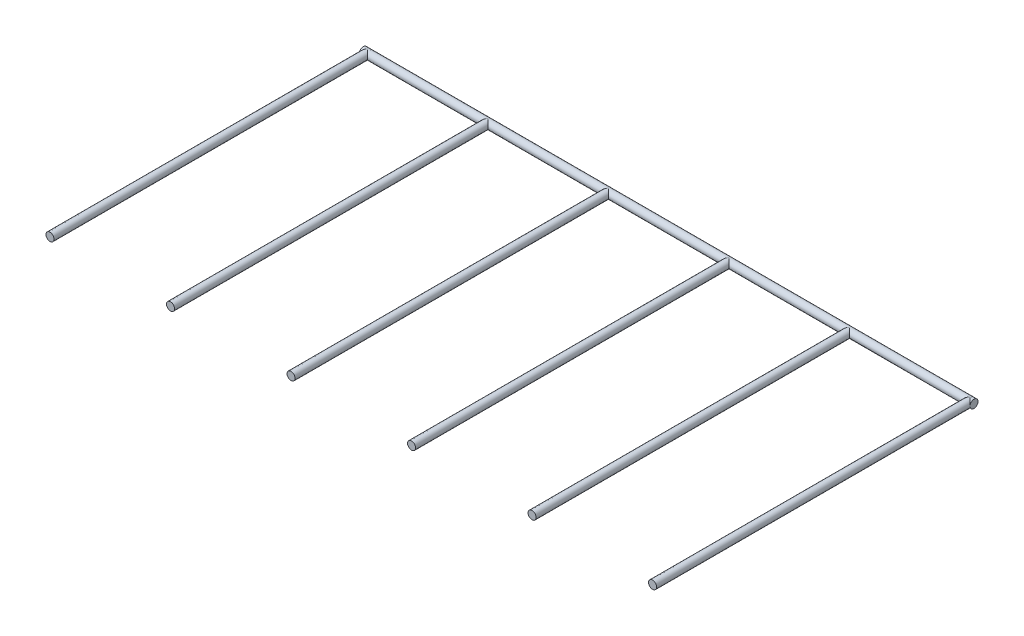
from build123d import *

# Parameters (mm, degrees)
SKETCH1_R           = 1.5875
BOSS_EXTRUDE1_DEPTH = 120.65
SKETCH3_R           = 1.5875
BOSS_EXTRUDE2_DEPTH = 125.4125
LPATTERN1_COUNT     = 6
LPATTERN1_PITCH     = 47.625


with BuildPart() as part:
    # Sketch1 → Boss-Extrude1 (new body, symmetric)
    with BuildSketch(Plane(origin=(0, 0, 0), x_dir=(0, 0, -1), z_dir=(1, 0, 0))):
        Circle(SKETCH1_R)
    extrude(amount=BOSS_EXTRUDE1_DEPTH, both=True)

    # Sketch3 → Boss-Extrude2 (add)
    with BuildSketch(Plane.XY):
        with Locations((-119.0625, 0)):
            Circle(SKETCH3_R)
    boss_extrude2 = extrude(amount=BOSS_EXTRUDE2_DEPTH)

    # LPattern1: Boss-Extrude2 ×6
    with Locations(*[(i * LPATTERN1_PITCH, 0, 0) for i in range(1, LPATTERN1_COUNT)]):
        add(boss_extrude2)


solid = part.part
